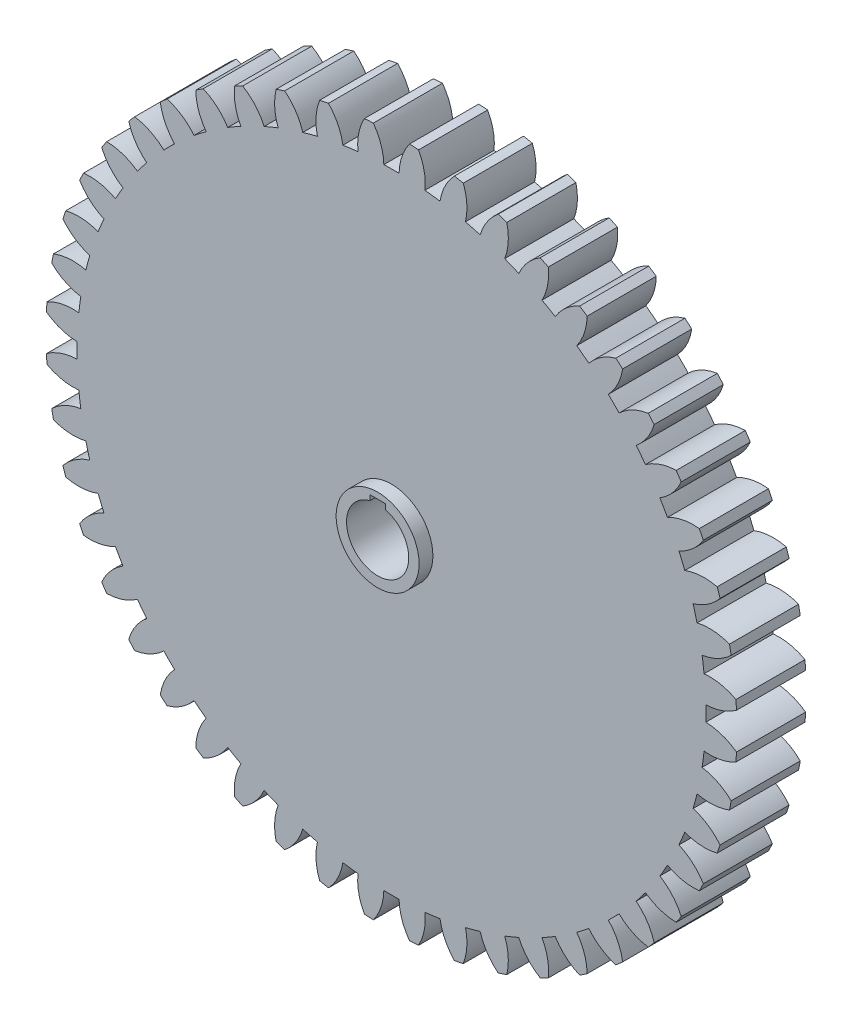
from build123d import *

# Parameters (mm, degrees)
SKETCH2_R               = 50
BOSS_EXTRUDE1_DEPTH     = 5
CUT_EXTRUDE1_DEPTH      = 71.887234394
SKETCH4_R               = 6
BOSS_EXTRUDE2_DEPTH     = 2
CUT_EXTRUDE6_DEPTH      = 72.721684308
CUT_EXTRUDE6_DEPTH_BACK = 72.721684308
CIRPATTERN1_COUNT       = 48


with BuildPart() as part:
    # Sketch2 → Boss-Extrude1 (new, symmetric)
    with BuildSketch(Plane.XY):
        Circle(SKETCH2_R)
    extrude(amount=BOSS_EXTRUDE1_DEPTH, both=True)

    # Sketch3 → Cut-Extrude1 (cut, symmetric)
    with BuildSketch(Plane.XY):
        with BuildLine():
            ThreePointArc((-2.617806339, 49.931423873), (-1.518056431, 47.825520361), (-1.100783842, 45.486682391))
            ThreePointArc((-1.100783842, 45.486682391), (0, 45.5), (1.100783842, 45.486682391))
            ThreePointArc((1.100783842, 45.486682391), (1.518056431, 47.825520361), (2.617806339, 49.931423873))
            ThreePointArc((2.617806339, 49.931423873), (0, 50), (-2.617806339, 49.931423873))
        make_face()
    cut_extrude1 = extrude(amount=CUT_EXTRUDE1_DEPTH, both=True, mode=Mode.SUBTRACT)

    # Sketch4 → Boss-Extrude2 (add)
    with BuildSketch(Plane.XY.offset(5)):
        Circle(SKETCH4_R)
        with BuildLine():
            ThreePointArc((1.125, 4.357106264), (0, -4.5), (-1.125, 4.357106264))
            Line((-1.125, 4.357106264), (-1.125, 5.107106264))
            Line((-1.125, 5.107106264), (1.125, 5.107106264))
            Line((1.125, 5.107106264), (1.125, 4.357106264))
        make_face(mode=Mode.SUBTRACT)
    boss_extrude2 = extrude(amount=BOSS_EXTRUDE2_DEPTH)

    # Mirror1: Boss-Extrude2 across plane
    add(boss_extrude2.mirror(Plane.XY))

    # Sketch4_4 → Cut-Extrude6 (cut, two sides: drawn at the far end of the back side and taken through both)
    with BuildSketch(Plane.XY.offset(5).offset(-CUT_EXTRUDE6_DEPTH_BACK)):
        with BuildLine():
            Line((1.125, 3.607106264), (-1.125, 3.607106264))
            Line((-1.125, 3.607106264), (-1.125, 4.357106264))
            ThreePointArc((-1.125, 4.357106264), (0, -4.5), (1.125, 4.357106264))
            Line((1.125, 4.357106264), (1.125, 3.607106264))
        make_face()
    extrude(amount=CUT_EXTRUDE6_DEPTH + CUT_EXTRUDE6_DEPTH_BACK, mode=Mode.SUBTRACT)

    # CirPattern1: Cut-Extrude1 ×48 about axis
    cirpattern1_axis = Axis((0, 0, -5), (0, 0, 1))
    for i in range(1, CIRPATTERN1_COUNT):
        add(cut_extrude1.rotate(cirpattern1_axis, i * 360 / CIRPATTERN1_COUNT), mode=Mode.SUBTRACT)


solid = part.part
